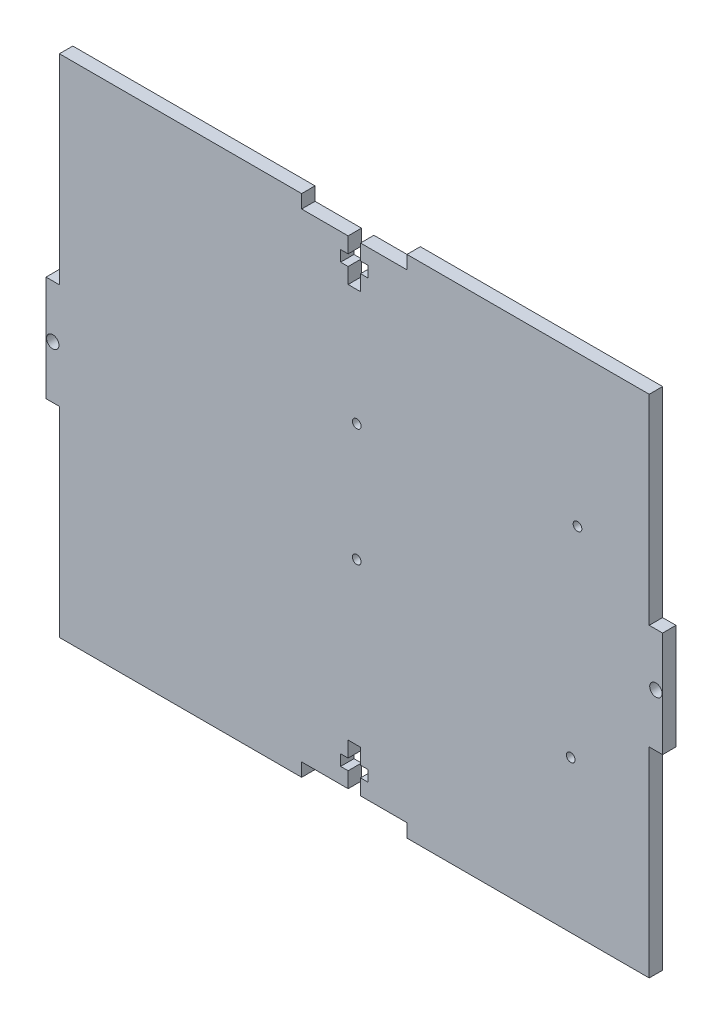
from build123d import *

# Parameters (mm, degrees)
SKETCH1_R           = 1.47
BOSS_EXTRUDE1_DEPTH = 1.5875
SKETCH3_R           = 1.0287
CUT_EXTRUDE1_DEPTH  = 4.175


with BuildPart() as part:
    # Sketch1 → Boss-Extrude1 (new body, symmetric)
    with BuildSketch(Plane.XY):
        Polygon((-12.5, 60), (-70, 60), (-70, 12.5), (-73.175, 12.5), (-73.175, -12.5), (-70, -12.5), (-70, -60), (-12.5, -60), (-12.5, -56.825), (-1.47, -56.825), (-1.47, -53.125), (-3.25, -53.125), (-3.25, -50.525), (-1.47, -50.525), (-1.47, -46.825), (1.47, -46.825), (1.47, -50.525), (3.25, -50.525), (3.25, -53.125), (1.47, -53.125), (1.47, -56.825), (12.5, -56.825), (12.5, -60), (70, -60), (70, -12.5), (73.175, -12.5), (73.175, 12.5), (70, 12.5), (70, 60), (12.5, 60), (12.5, 56.825), (1.47, 56.825), (1.47, 53.125), (3.25, 53.125), (3.25, 50.525), (1.47, 50.525), (1.47, 46.825), (-1.47, 46.825), (-1.47, 50.525), (-3.25, 50.525), (-3.25, 53.125), (-1.47, 53.125), (-1.47, 56.825), (-12.5, 56.825), align=None)
        with Locations((-71.5875, 0)):
            Circle(SKETCH1_R, mode=Mode.SUBTRACT)
        with Locations((71.5875, 0)):
            Circle(SKETCH1_R, mode=Mode.SUBTRACT)
    extrude(amount=BOSS_EXTRUDE1_DEPTH, both=True)

    # Sketch3 → Cut-Extrude1 (cut, through all)
    with BuildSketch(Plane(origin=(0, 0, -1.5875), x_dir=(-1, 0, 0), z_dir=(0, 0, -1))):
        with Locations((-51.375, -23.975)):
            Circle(SKETCH3_R)
        with Locations((-52.975, 24.325)):
            Circle(SKETCH3_R)
        with Locations((-0.575, -8.675)):
            Circle(SKETCH3_R)
        with Locations((-0.575, 19.225)):
            Circle(SKETCH3_R)
    extrude(amount=-CUT_EXTRUDE1_DEPTH, mode=Mode.SUBTRACT)


solid = part.part
